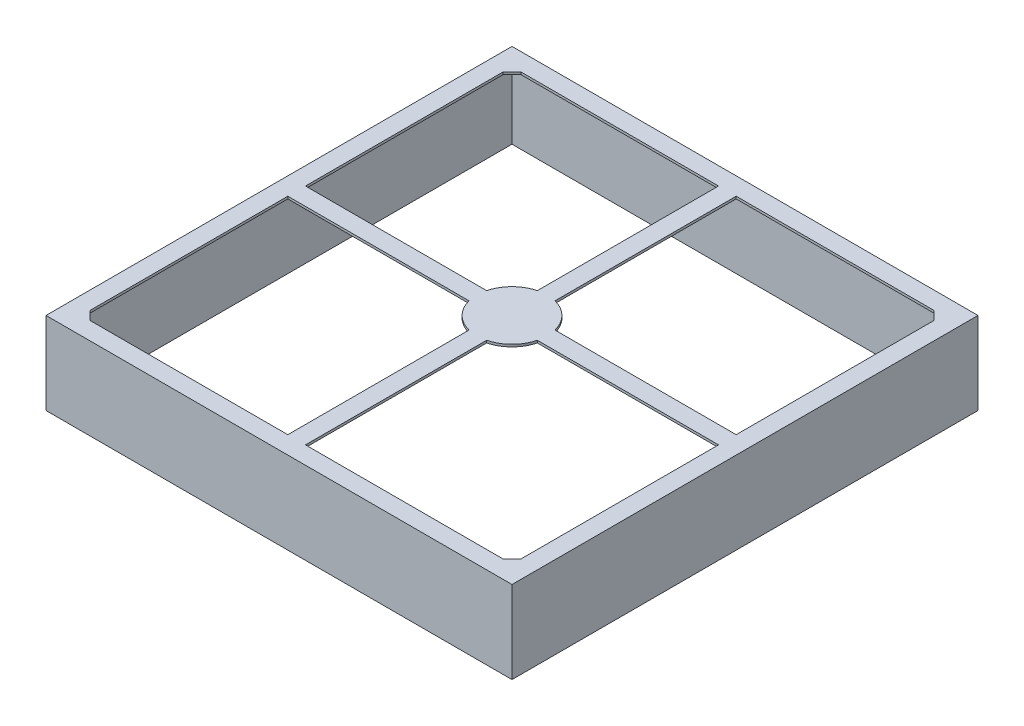
from build123d import *

# Parameters (mm, degrees)
SKETCH1_W           = 39.6
SKETCH1_H           = 39.6
BOSS_EXTRUDE1_DEPTH = 7
SHELL2_T            = -0.2
CUT_EXTRUDE1_DEPTH  = 8


with BuildPart() as part:
    # Sketch1 → Boss-Extrude1 (new body)
    with BuildSketch(Plane(origin=(0, 0, 0), x_dir=(1, 0, 0), z_dir=(0, 1, 0))):
        Rectangle(SKETCH1_W, SKETCH1_H)
    extrude(amount=BOSS_EXTRUDE1_DEPTH)

    # Shell2
    shell2_openings = [part.faces().sort_by_distance(p)[0] for p in [
        (0, 0, 0),
    ]]
    offset(amount=SHELL2_T, openings=shell2_openings, kind=Kind.INTERSECTION)

    # Sketch2 → Cut-Extrude1 (cut, through all)
    with BuildSketch(Plane(origin=(0, 0, 0), x_dir=(1, 0, 0), z_dir=(0, 1, 0))):
        with BuildLine():
            Line((17.55, -18.3), (0.75, -18.3))
            Line((0.75, -18.3), (0.75, -2.90473751))
            ThreePointArc((0.75, -2.90473751), (2.121320344, -2.121320344), (2.90473751, -0.75))
            Line((2.90473751, -0.75), (18.3, -0.75))
            Line((18.3, -0.75), (18.3, -17.55))
            Line((18.3, -17.55), (17.55, -18.3))
        make_face()
        with BuildLine():
            Line((17.55, 18.3), (0.75, 18.3))
            Line((0.75, 18.3), (0.75, 2.90473751))
            ThreePointArc((0.75, 2.90473751), (2.121320344, 2.121320344), (2.90473751, 0.75))
            Line((2.90473751, 0.75), (18.3, 0.75))
            Line((18.3, 0.75), (18.3, 17.55))
            Line((18.3, 17.55), (17.55, 18.3))
        make_face()
        with BuildLine():
            Line((-18.3, -17.55), (-18.3, -0.75))
            Line((-18.3, -0.75), (-2.90473751, -0.75))
            ThreePointArc((-2.90473751, -0.75), (-2.121320344, -2.121320344), (-0.75, -2.90473751))
            Line((-0.75, -2.90473751), (-0.75, -18.3))
            Line((-0.75, -18.3), (-17.55, -18.3))
            Line((-17.55, -18.3), (-18.3, -17.55))
        make_face()
        with BuildLine():
            Line((-0.75, 18.3), (-0.75, 2.90473751))
            ThreePointArc((-0.75, 2.90473751), (-2.121320344, 2.121320344), (-2.90473751, 0.75))
            Line((-2.90473751, 0.75), (-18.3, 0.75))
            Line((-18.3, 0.75), (-18.3, 17.55))
            Line((-18.3, 17.55), (-17.55, 18.3))
            Line((-17.55, 18.3), (-0.75, 18.3))
        make_face()
    extrude(amount=CUT_EXTRUDE1_DEPTH, mode=Mode.SUBTRACT)


solid = part.part
